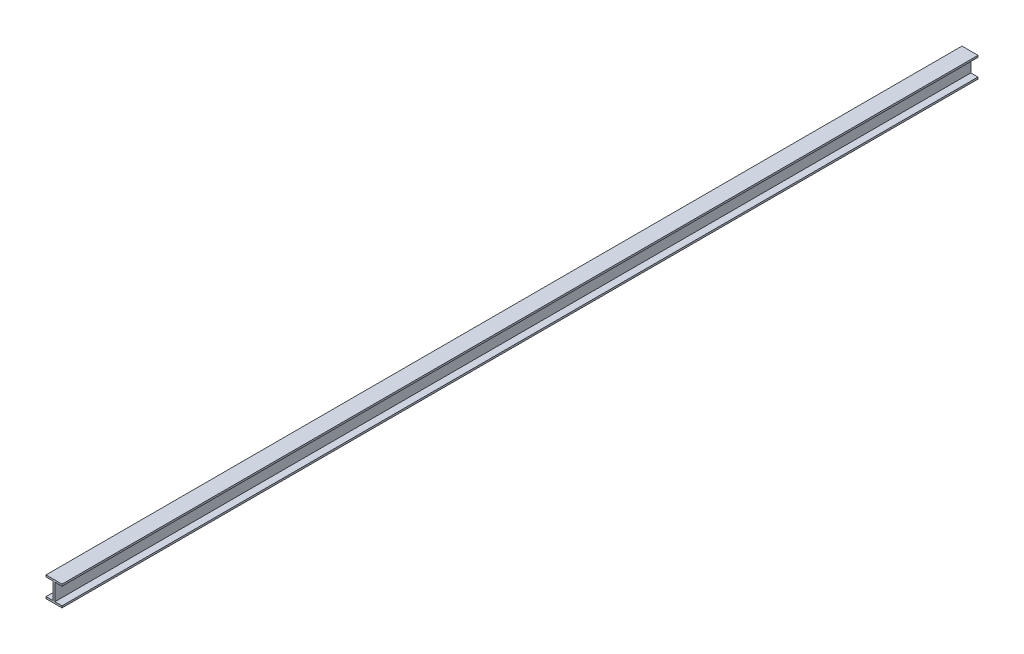
from build123d import *

# Parameters (mm, degrees)
BOSS_EXTRUDE1_DEPTH = 16000


with BuildPart() as part:
    # Sketch1 → Boss-Extrude1 (new body)
    with BuildSketch(Plane.XY):
        Polygon((156, -328), (280, -328), (280, -360), (0, -360), (0, -328), (124, -328), (124, -32), (0, -32), (0, 0), (280, 0), (280, -32), (156, -32), align=None)
    extrude(amount=BOSS_EXTRUDE1_DEPTH)


solid = part.part
